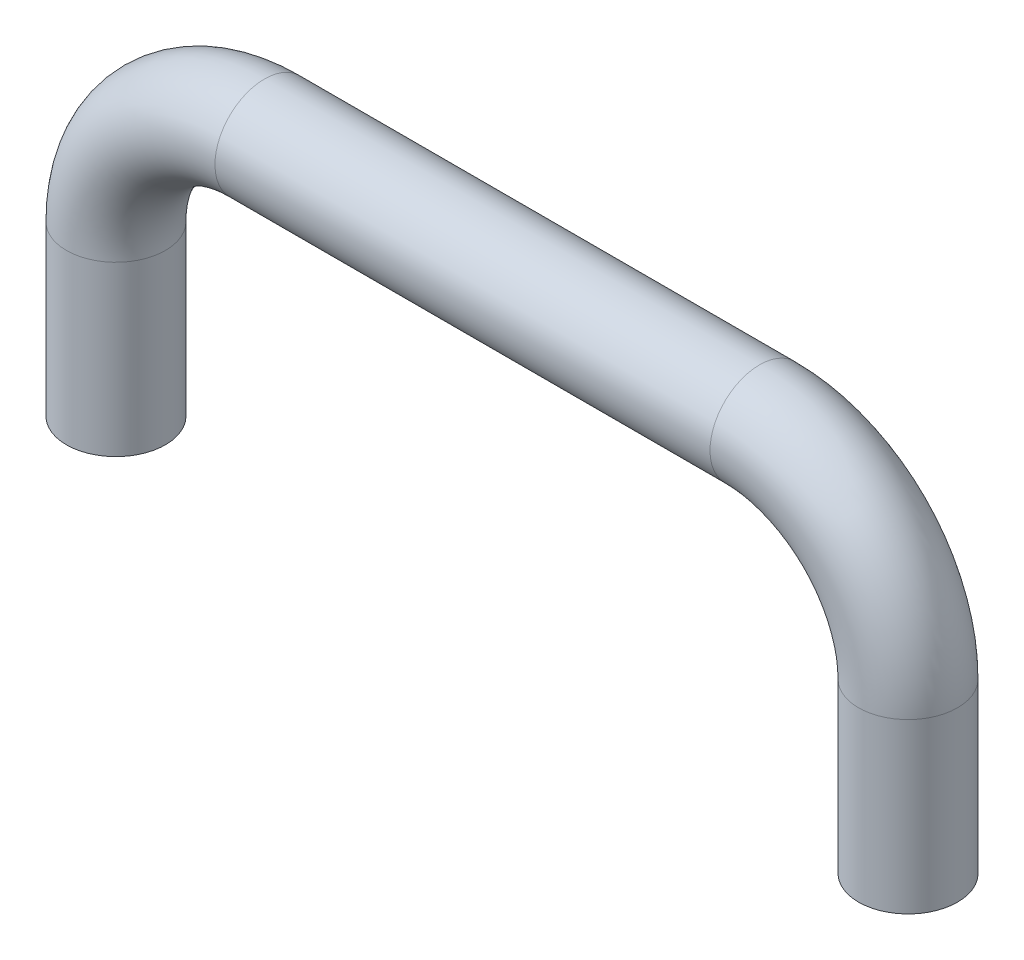
from build123d import *

# Parameters (mm, degrees)
SKETCH1_R  = 5
TAP1_D     = 4.134
TAP1_DEPTH = 10
TAP1_TIP   = 1.2419789


with BuildPart() as part:
    # Sweep1: sweep along a path in Sketch2
    with BuildLine(Plane.XY) as sweep1_path:
        Line((-40, 0), (-40, 17))
        ThreePointArc((-40, 17), (-35.606601718, 27.606601718), (-25, 32))
        Line((-25, 32), (25, 32))
        ThreePointArc((25, 32), (35.606601718, 27.606601718), (40, 17))
        Line((40, 17), (40, 0))
    # Sketch1 → Sweep1 (sweep)
    with BuildSketch(Plane(origin=(0, 0, 0), x_dir=(1, 0, 0), z_dir=(0, 1, 0))):
        with Locations((-40, 0)):
            Circle(SKETCH1_R)
    sweep(path=sweep1_path.line)

    # Tap1
    with Locations(Plane.XZ):
        with Locations((-40, 0), (40, 0)):
            Hole(TAP1_D / 2, depth=TAP1_DEPTH)
            with Locations((0, 0, -(TAP1_DEPTH + TAP1_TIP / 2))):  # 118° drill point
                Cone(0, TAP1_D / 2, TAP1_TIP, mode=Mode.SUBTRACT)


solid = part.part
